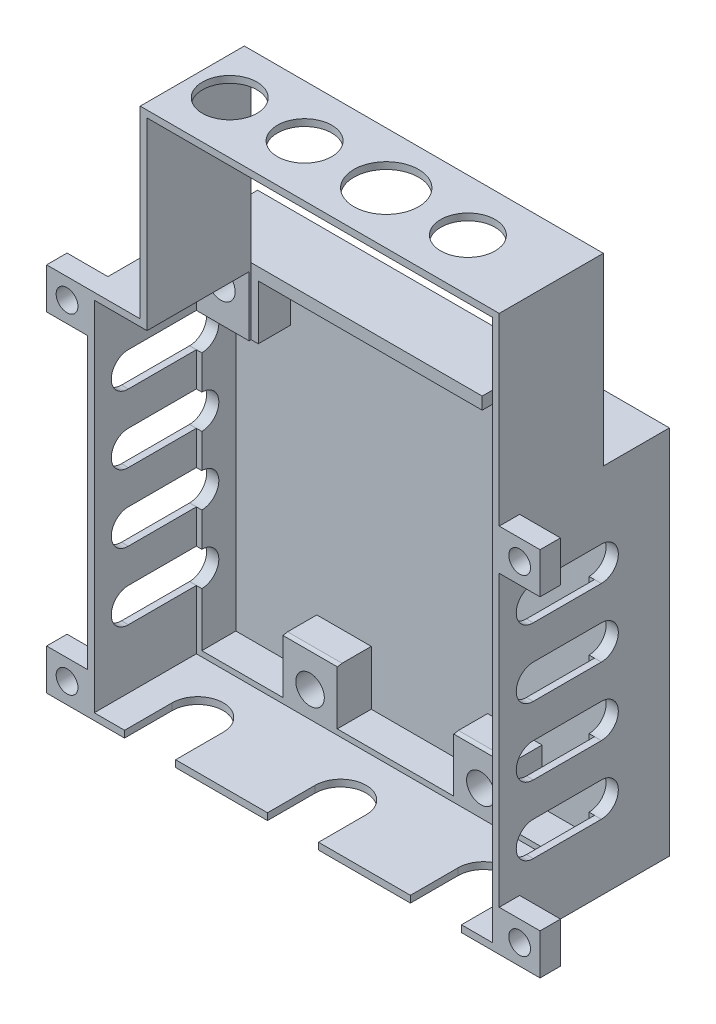
from build123d import *

# Parameters (mm, degrees)
CROQUIS1_W              = 60.5
CROQUIS1_H              = 54.5
SALIENTE_EXTRUIR1_DEPTH = 25
CROQUIS2_W              = 56.9
CROQUIS2_H              = 50.9
CORTAR_EXTRUIR1_DEPTH   = 15
CROQUIS3_R              = 2.1
CORTAR_EXTRUIR2_DEPTH   = 5
CORTAR_EXTRUIR3_DEPTH   = 5
CORTAR_EXTRUIR4_DEPTH   = 1.8
CORTAR_EXTRUIR6_START   = -1.8
CORTAR_EXTRUIR6_DEPTH   = 60.5
CROQUIS10_W             = 6
CROQUIS10_H             = 6
CROQUIS10_R             = 1.6
SALIENTE_EXTRUIR2_DEPTH = 3
CROQUIS11_W             = 58.5
CROQUIS11_H             = 52.5
CORTAR_EXTRUIR7_DEPTH   = 15
CORTAR_EXTRUIR8_START   = -9.8
CROQUIS13_W             = 33.95
CROQUIS13_H             = 0.3
CORTAR_EXTRUIR8_DEPTH   = 9.8
CORTAR_EXTRUIR9_START   = -15
CROQUIS14_W             = 50.75
CROQUIS14_H             = 1
CORTAR_EXTRUIR9_DEPTH   = 15
SALIENTE_EXTRUIR3_DEPTH = 15.3
CROQUIS17_R             = 4
CROQUIS17_R_2           = 4.75
CORTAR_EXTRUIR10_DEPTH  = 1


with BuildPart() as part:
    # Croquis1 → Saliente-Extruir1 (new body)
    with BuildSketch(Plane.XY):
        with Locations((-43.305557703, 3.094674556)):
            Rectangle(CROQUIS1_W, CROQUIS1_H)
    extrude(amount=SALIENTE_EXTRUIR1_DEPTH)

    # Croquis2 → Cortar-Extruir1 (cut)
    with BuildSketch(Plane.XY.offset(25)):
        with Locations((-43.305557703, 3.094674556)):
            Rectangle(CROQUIS2_W, CROQUIS2_H)
    extrude(amount=-CORTAR_EXTRUIR1_DEPTH, mode=Mode.SUBTRACT)

    # Croquis3 → Cortar-Extruir2 (cut)
    with BuildSketch(Plane.XY.offset(10)):
        with Locations((-68.955557703, 25.744674556)):
            Circle(CROQUIS3_R)
        with Locations((-55.855557703, -19.355325444)):
            Circle(CROQUIS3_R)
        with Locations((-30.755557703, -19.355325444)):
            Circle(CROQUIS3_R)
        with Locations((-17.655557703, 25.744674556)):
            Circle(CROQUIS3_R)
        Polygon((-71.755557703, 20.544674556), (-71.755557703, -22.355325444), (-59.855557703, -22.355325444), (-59.855557703, -14.355325444), (-51.855557703, -14.355325444), (-51.855557703, -22.355325444), (-34.755557703, -22.355325444), (-34.755557703, -14.355325444), (-26.755557703, -14.355325444), (-26.755557703, -22.355325444), (-14.855557703, -22.355325444), (-14.855557703, 20.544674556), (-22.855557703, 20.544674556), (-22.855557703, 28.544674556), (-63.755557703, 28.544674556), (-63.755557703, 20.544674556), align=None)
    extrude(amount=-CORTAR_EXTRUIR2_DEPTH, mode=Mode.SUBTRACT)

    # Croquis5 → Cortar-Extruir3 (cut)
    with BuildSketch(Plane(origin=(0, -22.355325444, 0), x_dir=(1, 0, 0), z_dir=(0, 1, 0))):
        with BuildLine():
            Line((-18.605557703, -18), (-18.605557703, -25))
            Line((-18.605557703, -25), (-26.105557703, -25))
            Line((-26.105557703, -25), (-26.105557703, -18))
            ThreePointArc((-26.105557703, -18), (-22.355557703, -14.25), (-18.605557703, -18))
        make_face()
        with BuildLine():
            Line((-39.605557703, -18), (-39.605557703, -25))
            Line((-39.605557703, -25), (-47.105557703, -25))
            Line((-47.105557703, -25), (-47.105557703, -18))
            ThreePointArc((-47.105557703, -18), (-43.355557703, -14.25), (-39.605557703, -18))
        make_face()
        with BuildLine():
            Line((-60.605557703, -18), (-60.605557703, -25))
            Line((-60.605557703, -25), (-68.105557703, -25))
            Line((-68.105557703, -25), (-68.105557703, -18))
            ThreePointArc((-68.105557703, -18), (-64.355557703, -14.25), (-60.605557703, -18))
        make_face()
    extrude(amount=-CORTAR_EXTRUIR3_DEPTH, mode=Mode.SUBTRACT)

    # Croquis6 → Cortar-Extruir4 (cut)
    with BuildSketch(Plane.XZ.offset(-28.544674556)):
        Polygon((-64.805557703, 17), (-21.805557703, 17), (-21.805557703, 10), (-22.855557703, 10), (-22.855557703, 5), (-30.855557703, 5), (-30.855557703, 10), (-64.805557703, 10), align=None)
    extrude(amount=-CORTAR_EXTRUIR4_DEPTH, mode=Mode.SUBTRACT)

    # Croquis9 → Cortar-Extruir6 (cut)
    with BuildSketch(Plane(origin=(-71.755557703, 0, 0), x_dir=(0, 0, -1), z_dir=(1, 0, 0)).offset(CORTAR_EXTRUIR6_START)):
        with BuildLine():
            Line((-10, 20.544674556), (-20, 20.544674556))
            ThreePointArc((-20, 20.544674556), (-22.5, 18.044674556), (-20, 15.544674556))
            Line((-20, 15.544674556), (-10, 15.544674556))
            ThreePointArc((-10, 15.544674556), (-7.5, 18.044674556), (-10, 20.544674556))
        make_face()
        with BuildLine():
            Line((-10, 10.544674556), (-20, 10.544674556))
            ThreePointArc((-20, 10.544674556), (-22.5, 8.044674556), (-20, 5.544674556))
            Line((-20, 5.544674556), (-10, 5.544674556))
            ThreePointArc((-10, 5.544674556), (-7.5, 8.044674556), (-10, 10.544674556))
        make_face()
        with BuildLine():
            Line((-10, 0.544674556), (-20, 0.544674556))
            ThreePointArc((-20, 0.544674556), (-22.5, -1.955325444), (-20, -4.455325444))
            Line((-20, -4.455325444), (-10, -4.455325444))
            ThreePointArc((-10, -4.455325444), (-7.5, -1.955325444), (-10, 0.544674556))
        make_face()
        with BuildLine():
            Line((-10, -9.455325444), (-20, -9.455325444))
            ThreePointArc((-20, -9.455325444), (-22.5, -11.955325444), (-20, -14.455325444))
            Line((-20, -14.455325444), (-10, -14.455325444))
            ThreePointArc((-10, -14.455325444), (-7.5, -11.955325444), (-10, -9.455325444))
        make_face()
    extrude(amount=CORTAR_EXTRUIR6_DEPTH, mode=Mode.SUBTRACT)

    # Croquis10 → Saliente-Extruir2 (add)
    with BuildSketch(Plane.XY.offset(25)):
        with Locations((-76.555557703, 27.344674556)):
            Rectangle(CROQUIS10_W, CROQUIS10_H)
        with Locations((-76.555557703, 27.344674556)):
            Circle(CROQUIS10_R, mode=Mode.SUBTRACT)
        with Locations((-10.055557703, 27.344674556)):
            Rectangle(CROQUIS10_W, CROQUIS10_H)
        with Locations((-10.055557703, 27.344674556)):
            Circle(CROQUIS10_R, mode=Mode.SUBTRACT)
        with Locations((-10.055557703, -21.155325444)):
            Rectangle(CROQUIS10_W, CROQUIS10_H)
        with Locations((-10.055557703, -21.155325444)):
            Circle(CROQUIS10_R, mode=Mode.SUBTRACT)
        with Locations((-76.555557703, -21.155325444)):
            Rectangle(CROQUIS10_W, CROQUIS10_H)
        with Locations((-76.555557703, -21.155325444)):
            Circle(CROQUIS10_R, mode=Mode.SUBTRACT)
    extrude(amount=-SALIENTE_EXTRUIR2_DEPTH)

    # Croquis11 → Cortar-Extruir7 (cut)
    with BuildSketch(Plane.XY.offset(25)):
        with Locations((-43.305557703, 3.094674556)):
            Rectangle(CROQUIS11_W, CROQUIS11_H)
    extrude(amount=-CORTAR_EXTRUIR7_DEPTH, mode=Mode.SUBTRACT)

    # Croquis13 → Cortar-Extruir8 (cut)
    with BuildSketch(Plane(origin=(0, 30.344674556, 0), x_dir=(1, 0, 0), z_dir=(0, 1, 0)).offset(CORTAR_EXTRUIR8_START)):
        with Locations((-47.830557703, -9.85)):
            Rectangle(CROQUIS13_W, CROQUIS13_H)
    extrude(amount=CORTAR_EXTRUIR8_DEPTH, mode=Mode.SUBTRACT)

    # Croquis14 → Cortar-Extruir9 (cut)
    with BuildSketch(Plane.XY.offset(25).offset(CORTAR_EXTRUIR9_START)):
        with Locations((-39.430557703, 29.844674556)):
            Rectangle(CROQUIS14_W, CROQUIS14_H)
    extrude(amount=CORTAR_EXTRUIR9_DEPTH, mode=Mode.SUBTRACT)

    # Croquis16 → Saliente-Extruir3 (add)
    with BuildSketch(Plane.XY.offset(25)):
        Polygon((-64.805557703, 30.344674556), (-64.805557703, 56.41412893), (-14.055557703, 56.41412893), (-14.055557703, 30.344674556), (-13.055557703, 30.344674556), (-13.055557703, 57.41412893), (-65.805557703, 57.41412893), (-65.805557703, 30.344674556), align=None)
    extrude(amount=-SALIENTE_EXTRUIR3_DEPTH)

    # Croquis17 → Cortar-Extruir10 (cut)
    with BuildSketch(Plane(origin=(0, 57.41412893, 0), x_dir=(1, 0, 0), z_dir=(0, 1, 0))):
        with Locations((-60.305557703, -17.35)):
            Circle(CROQUIS17_R)
        with Locations((-49.305557703, -17.35)):
            Circle(CROQUIS17_R)
        with Locations((-37.305557703, -17.35)):
            Circle(CROQUIS17_R_2)
        with Locations((-25.305557703, -17.35)):
            Circle(CROQUIS17_R)
    extrude(amount=-CORTAR_EXTRUIR10_DEPTH, mode=Mode.SUBTRACT)


solid = part.part
